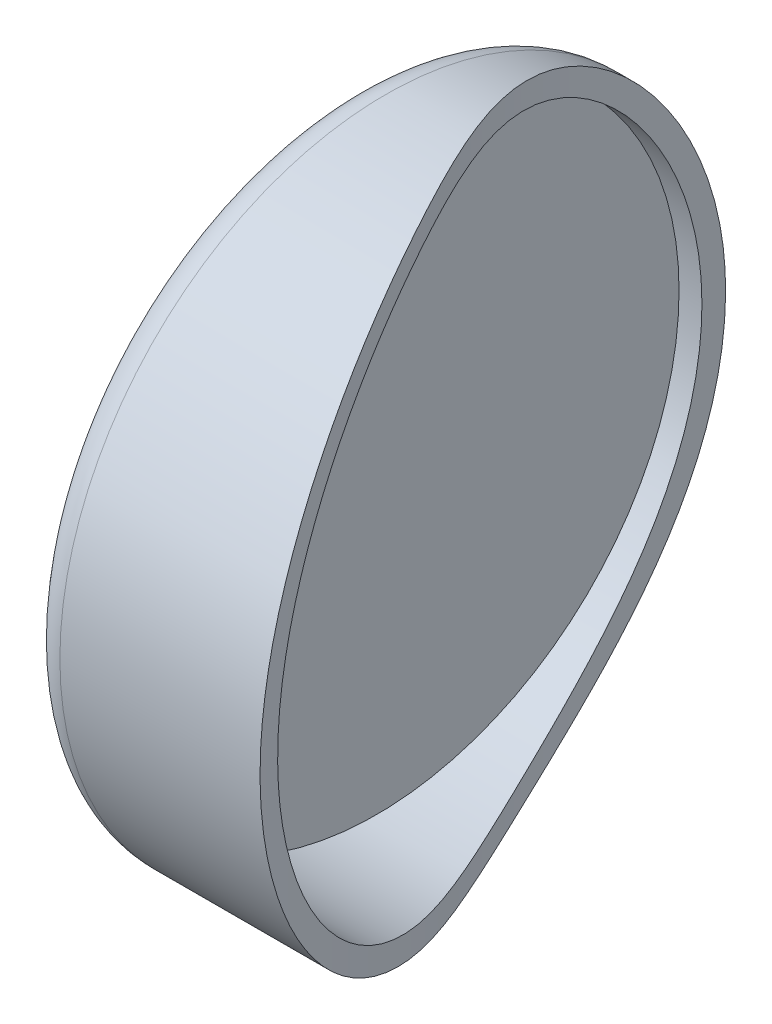
from build123d import *

# Parameters (mm, degrees)
SKETCH1_R           = 70
BOSS_EXTRUDE1_DEPTH = 50
SKETCH3_R           = 65
CUT_EXTRUDE1_DEPTH  = 45
CUT_EXTRUDE2_DEPTH  = 82.5
FILLET2_R           = 7
SKETCH5_R           = 50
BOSS_EXTRUDE2_DEPTH = 2


with BuildPart() as part:
    # Sketch1 → Boss-Extrude1 (new body)
    with BuildSketch(Plane(origin=(0, 0, 0), x_dir=(0, 0, -1), z_dir=(1, 0, 0))):
        Circle(SKETCH1_R)
    extrude(amount=BOSS_EXTRUDE1_DEPTH)

    # Sketch3 → Cut-Extrude1 (cut)
    with BuildSketch(Plane(origin=(50, 0, 0), x_dir=(0, 0, -1), z_dir=(1, 0, 0))):
        Circle(SKETCH3_R)
    extrude(amount=-CUT_EXTRUDE1_DEPTH, mode=Mode.SUBTRACT)

    # Sketch4 → Cut-Extrude2 (cut, symmetric)
    with BuildSketch(Plane(origin=(0, 0, 0), x_dir=(1, 0, 0), z_dir=(0, 1, 0))):
        with BuildLine():
            Line((50, -70), (50, 70))
            Line((50, 70), (10, 70))
            add(Edge.make_bspline(
                [(10, 70), (8.736205307, 29.113153139), (29.458127412, -5.568528558), (46.811482452, -55.943406632), (50, -70)],
                knots=[0, 0, 0, 0, 0.596241342, 1, 1, 1, 1], degree=3))
        make_face()
    extrude(amount=CUT_EXTRUDE2_DEPTH, both=True, mode=Mode.SUBTRACT)

    # Fillet2
    fillet2_edges = [part.edges().sort_by_distance(p)[0] for p in [
        (0, 0, 70),
    ]]
    fillet(fillet2_edges, radius=FILLET2_R)

    # Sketch5 → Boss-Extrude2 (add)
    with BuildSketch(Plane.ZY):
        Circle(SKETCH5_R)
    extrude(amount=BOSS_EXTRUDE2_DEPTH)


solid = part.part
